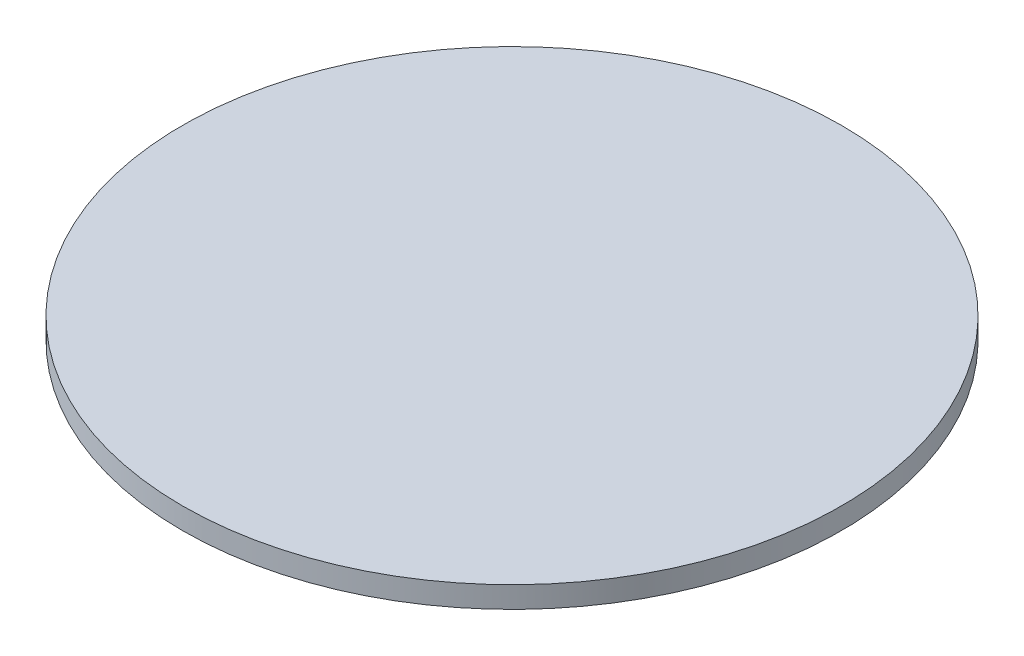
from build123d import *

# Parameters (mm, degrees)
SKETCH2_R           = 152.4
BOSS_EXTRUDE1_DEPTH = 9.906


with BuildPart() as part:
    # Sketch2 → Boss-Extrude1 (new body)
    with BuildSketch(Plane(origin=(0, 0, 0), x_dir=(1, 0, 0), z_dir=(0, 1, 0))):
        Circle(SKETCH2_R)
    extrude(amount=BOSS_EXTRUDE1_DEPTH)


solid = part.part
